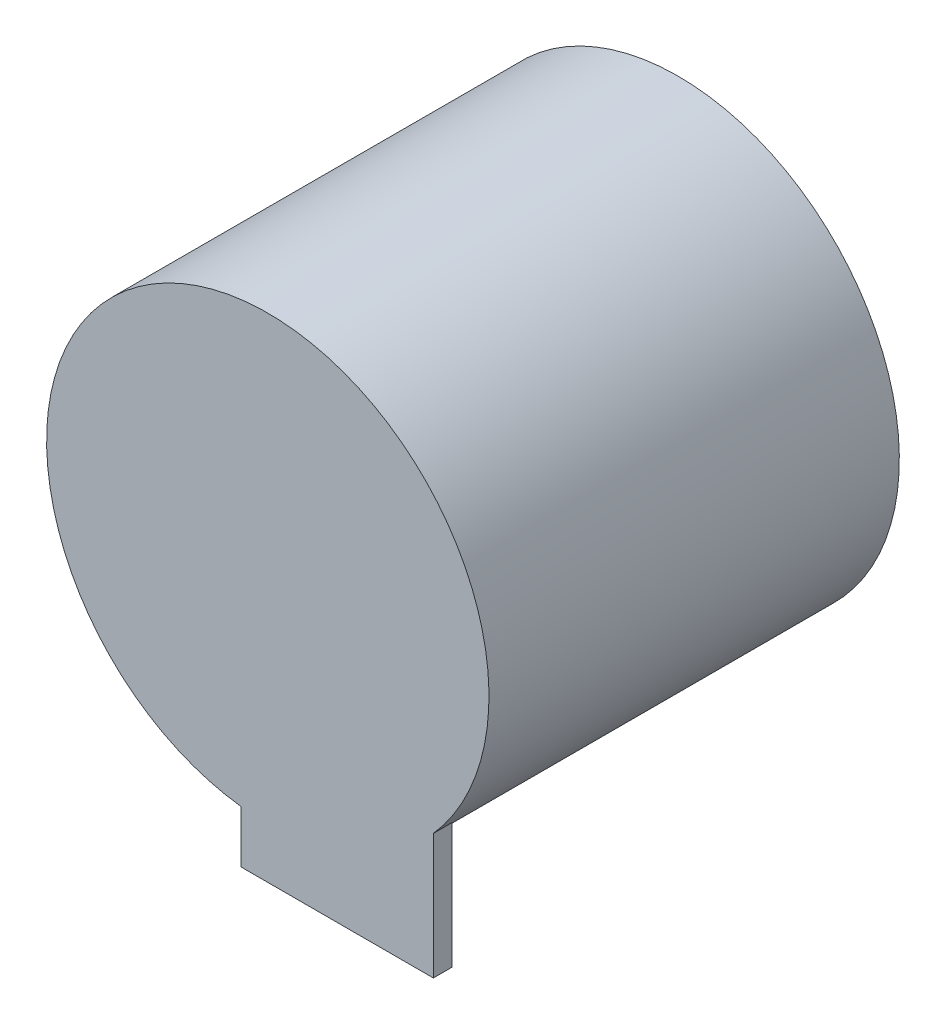
from build123d import *

# Parameters (mm, degrees)
SKETCH1_R           = 23.5
BOSS_EXTRUDE1_DEPTH = 21.8
SKETCH2_W           = 20.417368514
SKETCH2_H           = 15.313025903
BOSS_EXTRUDE2_DEPTH = 2


with BuildPart() as part:
    # Sketch1 → Boss-Extrude1 (new body, symmetric)
    with BuildSketch(Plane(origin=(-36.272491561, 0, 0), x_dir=(-1, 0, 0), z_dir=(0, 0, -1))):
        with Locations((-36.272491561, 0)):
            Circle(SKETCH1_R)
    extrude(amount=BOSS_EXTRUDE1_DEPTH, both=True)

    # Sketch2 → Boss-Extrude2 (add)
    with BuildSketch(Plane.XY.offset(21.8)):
        with Locations((7.381083838, -21.231446412)):
            Rectangle(SKETCH2_W, SKETCH2_H)
    extrude(amount=-BOSS_EXTRUDE2_DEPTH)


solid = part.part
